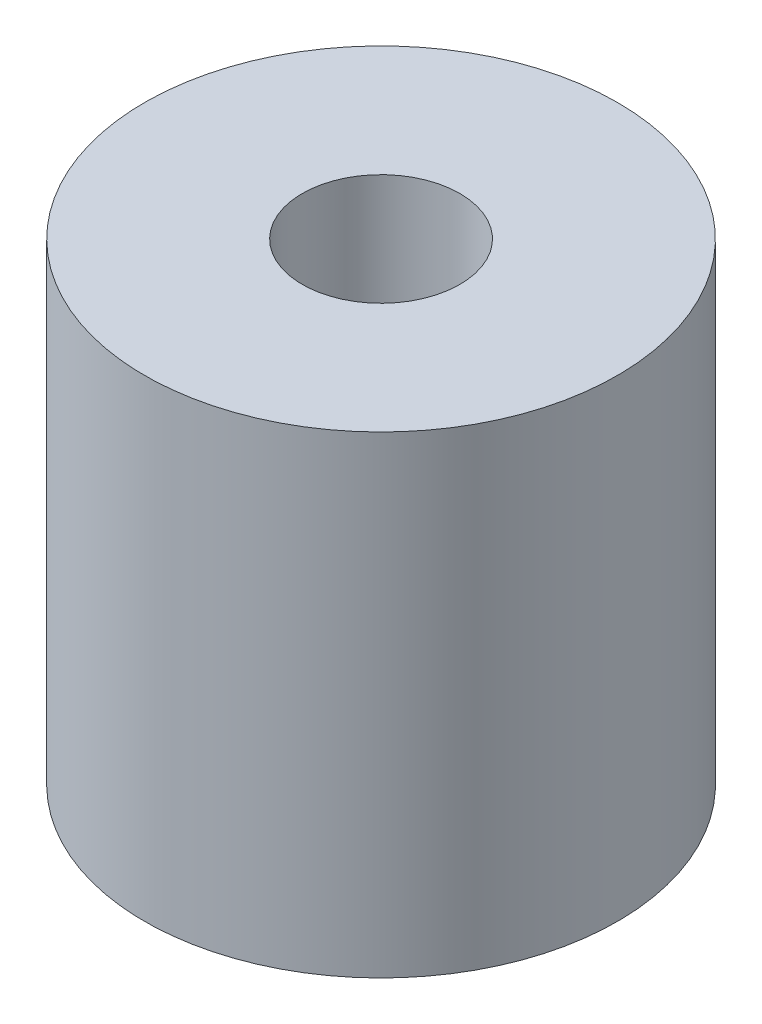
from build123d import *


with BuildPart() as part:
    # Эскиз1 → Повернуть1 (revolve)
    with BuildSketch(Plane.XY):
        Polygon((10, 0), (10, 60), (23.414569556, 60), (30, 60), (30, 0), (23.414569556, 0), align=None)
    revolve(axis=Axis((0, -14.792925727, 0), (0, 1, 0)))


solid = part.part
